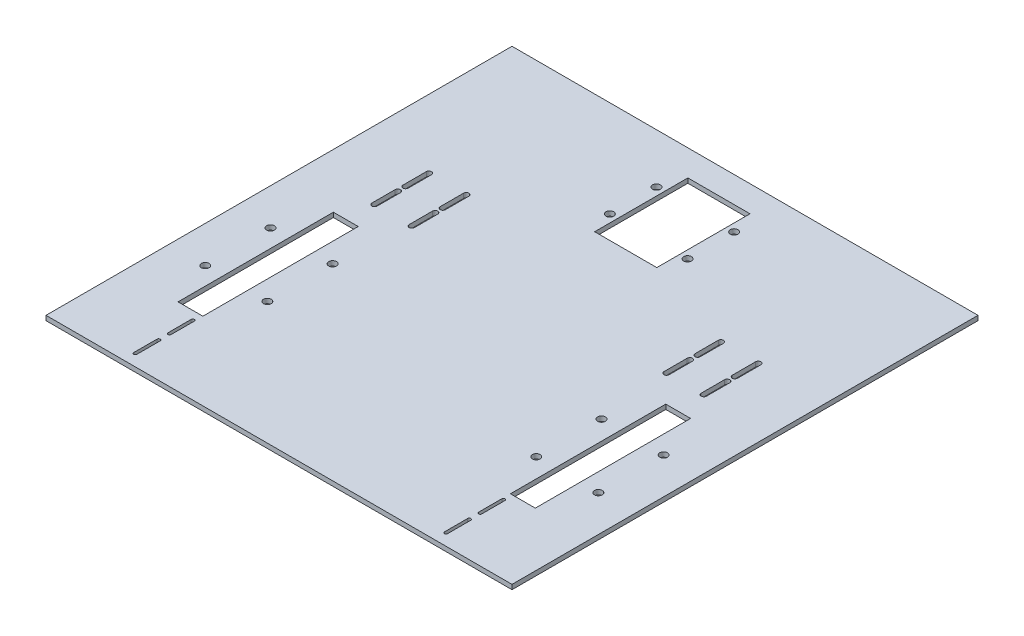
from build123d import *

# Parameters (mm, degrees)
SKETCH1_W           = 300
SKETCH1_H           = 300
BOSS_EXTRUDE1_DEPTH = 3
SKETCH2_W           = 16
SKETCH2_H           = 100
CUT_EXTRUDE2_DEPTH  = 3
SKETCH3_W           = 16
SKETCH3_H           = 100
CUT_EXTRUDE3_DEPTH  = 3
SKETCH5_W           = 40
SKETCH5_H           = 60
CUT_EXTRUDE4_DEPTH  = 3
SKETCH6_R           = 2.5
CUT_EXTRUDE5_DEPTH  = 3
CUT_EXTRUDE6_DEPTH  = 3
CUT_EXTRUDE7_DEPTH  = 3


with BuildPart() as part:
    # Sketch1 → Boss-Extrude1 (new body)
    with BuildSketch(Plane(origin=(0, 0, 0), x_dir=(1, 0, 0), z_dir=(0, 1, 0))):
        Rectangle(SKETCH1_W, SKETCH1_H)
    extrude(amount=BOSS_EXTRUDE1_DEPTH)

    # Sketch2 → Cut-Extrude2 (cut)
    with BuildSketch(Plane(origin=(0, 3, 0), x_dir=(1, 0, 0), z_dir=(0, 1, 0))):
        with Locations((-106.999981758, -49.997456266)):
            Rectangle(SKETCH2_W, SKETCH2_H)
    extrude(amount=-CUT_EXTRUDE2_DEPTH, mode=Mode.SUBTRACT)

    # Sketch3 → Cut-Extrude3 (cut)
    with BuildSketch(Plane(origin=(0, 3, 0), x_dir=(1, 0, 0), z_dir=(0, 1, 0))):
        with Locations((106.997905593, -50.002067411)):
            Rectangle(SKETCH3_W, SKETCH3_H)
    extrude(amount=-CUT_EXTRUDE3_DEPTH, mode=Mode.SUBTRACT)

    # Sketch5 → Cut-Extrude4 (cut)
    with BuildSketch(Plane(origin=(0, 3, 0), x_dir=(1, 0, 0), z_dir=(0, 1, 0))):
        with Locations((0.000226616, 103.221805272)):
            Rectangle(SKETCH5_W, SKETCH5_H)
    extrude(amount=-CUT_EXTRUDE4_DEPTH, mode=Mode.SUBTRACT)

    # Sketch6 → Cut-Extrude5 (cut)
    with BuildSketch(Plane(origin=(0, 3, 0), x_dir=(1, 0, 0), z_dir=(0, 1, 0))):
        with Locations((-126.465787007, -29.019127059)):
            Circle(SKETCH6_R)
        with Locations((-86.465787007, -29.019127059)):
            Circle(SKETCH6_R)
        with Locations((-126.465787007, -71.019127059)):
            Circle(SKETCH6_R)
        with Locations((-86.465787007, -71.019127059)):
            Circle(SKETCH6_R)
        with Locations((86.681368776, -29.075116819)):
            Circle(SKETCH6_R)
        with Locations((86.681368776, -71.075116819)):
            Circle(SKETCH6_R)
        with Locations((126.681368776, -29.075116819)):
            Circle(SKETCH6_R)
        with Locations((126.681368776, -71.075116819)):
            Circle(SKETCH6_R)
        with Locations((-25, 118)):
            Circle(SKETCH6_R)
        with Locations((-25, 88)):
            Circle(SKETCH6_R)
        with Locations((25, 118)):
            Circle(SKETCH6_R)
        with Locations((25, 88)):
            Circle(SKETCH6_R)
    extrude(amount=-CUT_EXTRUDE5_DEPTH, mode=Mode.SUBTRACT)

    # Sketch7 → Cut-Extrude6 (cut)
    with BuildSketch(Plane(origin=(0, 3, 0), x_dir=(1, 0, 0), z_dir=(0, 1, 0))):
        with BuildLine():
            Line((-104.3, 52.5), (-104.3, 37.5))
            ThreePointArc((-104.3, 37.5), (-106, 35.8), (-107.7, 37.5))
            Line((-107.7, 37.5), (-107.7, 52.5))
            ThreePointArc((-107.7, 52.5), (-106, 54.2), (-104.3, 52.5))
        make_face()
        with BuildLine():
            Line((-104.3, 32.5), (-104.3, 17.5))
            ThreePointArc((-104.3, 17.5), (-106, 15.8), (-107.7, 17.5))
            Line((-107.7, 17.5), (-107.7, 32.5))
            ThreePointArc((-107.7, 32.5), (-106, 34.2), (-104.3, 32.5))
        make_face()
        with BuildLine():
            Line((-80.3, 52.5), (-80.3, 37.5))
            ThreePointArc((-80.3, 37.5), (-82, 35.8), (-83.7, 37.5))
            Line((-83.7, 37.5), (-83.7, 52.5))
            ThreePointArc((-83.7, 52.5), (-82, 54.2), (-80.3, 52.5))
        make_face()
        with BuildLine():
            Line((-80.3, 32.5), (-80.3, 17.5))
            ThreePointArc((-80.3, 17.5), (-82, 15.8), (-83.7, 17.5))
            Line((-83.7, 17.5), (-83.7, 32.5))
            ThreePointArc((-83.7, 32.5), (-82, 34.2), (-80.3, 32.5))
        make_face()
        with BuildLine():
            Line((83.7, 52.5), (83.7, 37.5))
            ThreePointArc((83.7, 37.5), (82, 35.8), (80.3, 37.5))
            Line((80.3, 37.5), (80.3, 52.5))
            ThreePointArc((80.3, 52.5), (82, 54.2), (83.7, 52.5))
        make_face()
        with BuildLine():
            Line((83.7, 32.5), (83.7, 17.5))
            ThreePointArc((83.7, 17.5), (82, 15.8), (80.3, 17.5))
            Line((80.3, 17.5), (80.3, 32.5))
            ThreePointArc((80.3, 32.5), (82, 34.2), (83.7, 32.5))
        make_face()
        with BuildLine():
            Line((107.7, 52.5), (107.7, 37.5))
            ThreePointArc((107.7, 37.5), (106, 35.8), (104.3, 37.5))
            Line((104.3, 37.5), (104.3, 52.5))
            ThreePointArc((104.3, 52.5), (106, 54.2), (107.7, 52.5))
        make_face()
        with BuildLine():
            Line((107.7, 32.5), (107.7, 17.5))
            ThreePointArc((107.7, 17.5), (106, 15.8), (104.3, 17.5))
            Line((104.3, 17.5), (104.3, 32.5))
            ThreePointArc((104.3, 32.5), (106, 34.2), (107.7, 32.5))
        make_face()
    extrude(amount=-CUT_EXTRUDE6_DEPTH, mode=Mode.SUBTRACT)

    # Sketch8 → Cut-Extrude7 (cut)
    with BuildSketch(Plane(origin=(0, 3, 0), x_dir=(1, 0, 0), z_dir=(0, 1, 0))):
        with BuildLine():
            Line((-99, -105.5), (-99, -120.5))
            ThreePointArc((-99, -120.5), (-100, -121.5), (-101, -120.5))
            Line((-101, -120.5), (-101, -105.5))
            ThreePointArc((-101, -105.5), (-100, -104.5), (-99, -105.5))
        make_face()
        with BuildLine():
            Line((-99, -127.5), (-99, -142.5))
            ThreePointArc((-99, -142.5), (-100, -143.5), (-101, -142.5))
            Line((-101, -142.5), (-101, -127.5))
            ThreePointArc((-101, -127.5), (-100, -126.5), (-99, -127.5))
        make_face()
        with BuildLine():
            Line((101, -105.5), (101, -120.5))
            ThreePointArc((101, -120.5), (100, -121.5), (99, -120.5))
            Line((99, -120.5), (99, -105.5))
            ThreePointArc((99, -105.5), (100, -104.5), (101, -105.5))
        make_face()
        with BuildLine():
            Line((101, -127.5), (101, -142.5))
            ThreePointArc((101, -142.5), (100, -143.5), (99, -142.5))
            Line((99, -142.5), (99, -127.5))
            ThreePointArc((99, -127.5), (100, -126.5), (101, -127.5))
        make_face()
    extrude(amount=-CUT_EXTRUDE7_DEPTH, mode=Mode.SUBTRACT)


solid = part.part
